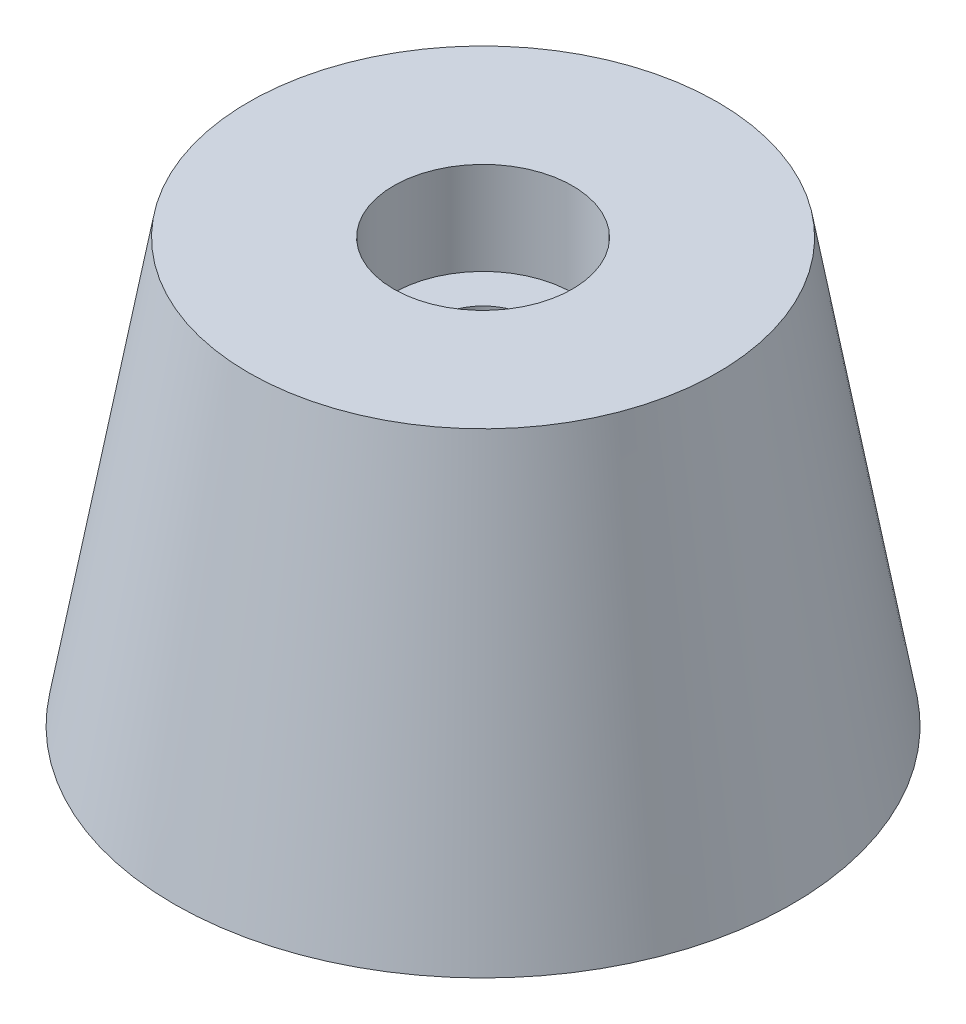
from build123d import *

# Parameters (mm, degrees)
SKETCH1_R                                        = 19
BOSS_EXTRUDE1_DEPTH                              = 26
BOSS_EXTRUDE1_TAPER                              = 10
CBORE_FOR_M5_PAN_HEAD_MACHINE_SCREW1_D           = 5.8
CBORE_FOR_M5_PAN_HEAD_MACHINE_SCREW1_CBORE_D     = 11
CBORE_FOR_M5_PAN_HEAD_MACHINE_SCREW1_CBORE_DEPTH = 5.7


with BuildPart() as part:
    # Sketch1 → Boss-Extrude1 (new body)
    with BuildSketch(Plane(origin=(0, 0, 0), x_dir=(1, 0, 0), z_dir=(0, 1, 0))):
        Circle(SKETCH1_R)
    extrude(amount=BOSS_EXTRUDE1_DEPTH, taper=BOSS_EXTRUDE1_TAPER)

    # CBORE for M5 Pan Head Machine Screw1 (through all)
    with Locations(Plane(origin=(0, 26, 0), x_dir=(1, 0, 0), z_dir=(0, 1, 0))):
        with Locations((0, 0)):
            CounterBoreHole(CBORE_FOR_M5_PAN_HEAD_MACHINE_SCREW1_D / 2, CBORE_FOR_M5_PAN_HEAD_MACHINE_SCREW1_CBORE_D / 2, CBORE_FOR_M5_PAN_HEAD_MACHINE_SCREW1_CBORE_DEPTH)


solid = part.part
